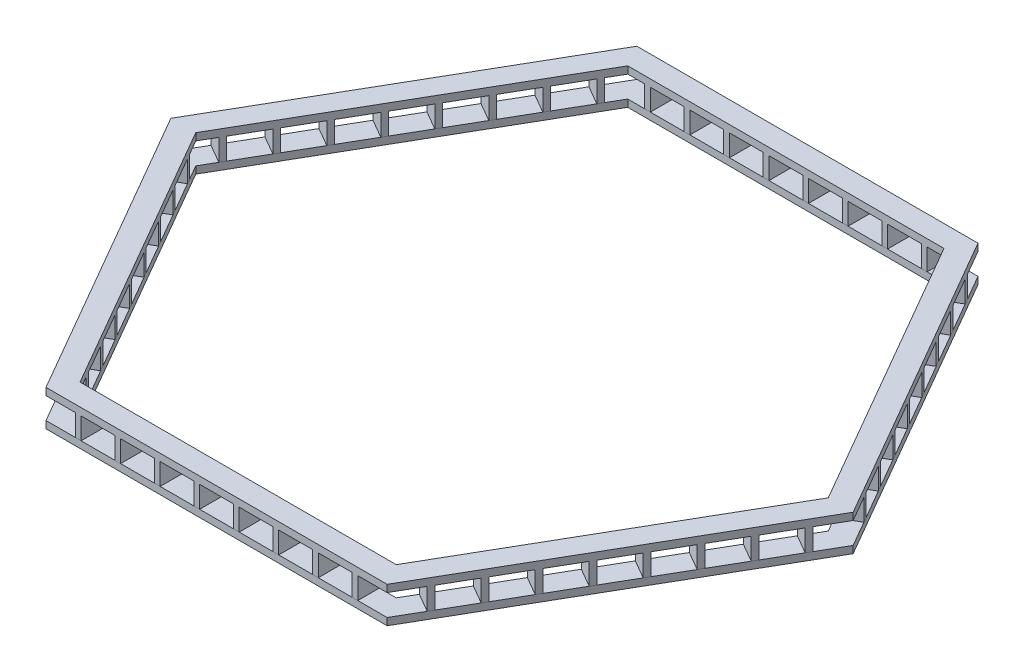
from build123d import *

# Parameters (mm, degrees)
EXTRUDE_2_DEPTH          = 50
SKETCH_2_W               = 40
SKETCH_2_H               = 150
EXTRUDE_3_DEPTH          = 150
EXTRUDE_3_2_DEPTH        = 150
EXTRUDE_3_3_DEPTH        = 150
EXTRUDE_3_4_DEPTH        = 150
EXTRUDE_3_5_DEPTH        = 150
EXTRUDE_3_6_DEPTH        = 150
EXTRUDE_3_7_DEPTH        = 150
EXTRUDE_3_8_DEPTH        = 150
PATTERN_CIRCULAR_2_COUNT = 6
EXTRUDE_5_DEPTH          = 50


with BuildPart() as part:
    # 草图1 → 凸台-拉伸2 (new body)
    with BuildSketch(Plane(origin=(0, 0, 0), x_dir=(1, 0, 0), z_dir=(0, 1, 0))):
        Polygon((-1186.602540378, -2055.255888326), (1186.602540378, -2055.255888326), (2373.205080757, 0), (1186.602540378, 2055.255888326), (-1186.602540378, 2055.255888326), (-2373.205080757, 0), align=None)
        Polygon((-1100, -1905.255888326), (1100, -1905.255888326), (2200, 0), (1100, 1905.255888326), (-1100, 1905.255888326), (-2200, 0), align=None, mode=Mode.SUBTRACT)
    extrude(amount=EXTRUDE_2_DEPTH)


with BuildPart() as body_2:
    # 草图2 → 凸台-拉伸3 (new body)
    with BuildSketch(Plane(origin=(0, 50, 0), x_dir=(1, 0, 0), z_dir=(0, 1, 0))):
        with Locations((137.5, 1980.255888326)):
            Rectangle(SKETCH_2_W, SKETCH_2_H)
    extrude(amount=EXTRUDE_3_DEPTH)


with BuildPart() as body_3:
    # 草图2 → Extrude 3 2 (new body)
    with BuildSketch(Plane(origin=(0, 50, 0), x_dir=(1, 0, 0), z_dir=(0, 1, 0))):
        with Locations((412.5, 1980.255888326)):
            Rectangle(SKETCH_2_W, SKETCH_2_H)
    extrude(amount=EXTRUDE_3_2_DEPTH)


with BuildPart() as body_4:
    # 草图2 → Extrude 3 3 (new body)
    with BuildSketch(Plane(origin=(0, 50, 0), x_dir=(1, 0, 0), z_dir=(0, 1, 0))):
        with Locations((687.5, 1980.255888326)):
            Rectangle(SKETCH_2_W, SKETCH_2_H)
    extrude(amount=EXTRUDE_3_3_DEPTH)


with BuildPart() as body_5:
    # 草图2 → Extrude 3 4 (new body)
    with BuildSketch(Plane(origin=(0, 50, 0), x_dir=(1, 0, 0), z_dir=(0, 1, 0))):
        with Locations((962.5, 1980.255888326)):
            Rectangle(SKETCH_2_W, SKETCH_2_H)
    extrude(amount=EXTRUDE_3_4_DEPTH)


with BuildPart() as body_6:
    # 草图2 → Extrude 3 5 (new body)
    with BuildSketch(Plane(origin=(0, 50, 0), x_dir=(1, 0, 0), z_dir=(0, 1, 0))):
        with Locations((-412.5, 1980.255888326)):
            Rectangle(SKETCH_2_W, SKETCH_2_H)
    extrude(amount=EXTRUDE_3_5_DEPTH)


with BuildPart() as body_7:
    # 草图2 → Extrude 3 6 (new body)
    with BuildSketch(Plane(origin=(0, 50, 0), x_dir=(1, 0, 0), z_dir=(0, 1, 0))):
        with Locations((-962.5, 1980.255888326)):
            Rectangle(SKETCH_2_W, SKETCH_2_H)
    extrude(amount=EXTRUDE_3_6_DEPTH)


with BuildPart() as body_8:
    # 草图2 → Extrude 3 7 (new body)
    with BuildSketch(Plane(origin=(0, 50, 0), x_dir=(1, 0, 0), z_dir=(0, 1, 0))):
        with Locations((-687.5, 1980.255888326)):
            Rectangle(SKETCH_2_W, SKETCH_2_H)
    extrude(amount=EXTRUDE_3_7_DEPTH)


with BuildPart() as body_9:
    # 草图2 → Extrude 3 8 (new body)
    with BuildSketch(Plane(origin=(0, 50, 0), x_dir=(1, 0, 0), z_dir=(0, 1, 0))):
        with Locations((-137.5, 1980.255888326)):
            Rectangle(SKETCH_2_W, SKETCH_2_H)
    extrude(amount=EXTRUDE_3_8_DEPTH)


with BuildPart() as pattern_circular_2_1:
    # 阵列(圆周)2: pattern copy
    add(body_5.part.rotate(Axis((0, 0, 0), (0, 1, 0)), 1 * 360 / PATTERN_CIRCULAR_2_COUNT))


with BuildPart() as pattern_circular_2_2:
    # 阵列(圆周)2: pattern copy
    add(body_5.part.rotate(Axis((0, 0, 0), (0, 1, 0)), 2 * 360 / PATTERN_CIRCULAR_2_COUNT))


with BuildPart() as pattern_circular_2_3:
    # 阵列(圆周)2: pattern copy
    add(body_5.part.rotate(Axis((0, 0, 0), (0, 1, 0)), 3 * 360 / PATTERN_CIRCULAR_2_COUNT))


with BuildPart() as pattern_circular_2_4:
    # 阵列(圆周)2: pattern copy
    add(body_5.part.rotate(Axis((0, 0, 0), (0, 1, 0)), 4 * 360 / PATTERN_CIRCULAR_2_COUNT))


with BuildPart() as pattern_circular_2_5:
    # 阵列(圆周)2: pattern copy
    add(body_5.part.rotate(Axis((0, 0, 0), (0, 1, 0)), 5 * 360 / PATTERN_CIRCULAR_2_COUNT))


with BuildPart() as pattern_circular_2_6:
    # 阵列(圆周)2: pattern copy
    add(body_3.part.rotate(Axis((0, 0, 0), (0, 1, 0)), 1 * 360 / PATTERN_CIRCULAR_2_COUNT))


with BuildPart() as pattern_circular_2_7:
    # 阵列(圆周)2: pattern copy
    add(body_3.part.rotate(Axis((0, 0, 0), (0, 1, 0)), 2 * 360 / PATTERN_CIRCULAR_2_COUNT))


with BuildPart() as pattern_circular_2_8:
    # 阵列(圆周)2: pattern copy
    add(body_3.part.rotate(Axis((0, 0, 0), (0, 1, 0)), 3 * 360 / PATTERN_CIRCULAR_2_COUNT))


with BuildPart() as pattern_circular_2_9:
    # 阵列(圆周)2: pattern copy
    add(body_3.part.rotate(Axis((0, 0, 0), (0, 1, 0)), 4 * 360 / PATTERN_CIRCULAR_2_COUNT))


with BuildPart() as pattern_circular_2_10:
    # 阵列(圆周)2: pattern copy
    add(body_3.part.rotate(Axis((0, 0, 0), (0, 1, 0)), 5 * 360 / PATTERN_CIRCULAR_2_COUNT))


with BuildPart() as pattern_circular_2_11:
    # 阵列(圆周)2: pattern copy
    add(body_7.part.rotate(Axis((0, 0, 0), (0, 1, 0)), 1 * 360 / PATTERN_CIRCULAR_2_COUNT))


with BuildPart() as pattern_circular_2_12:
    # 阵列(圆周)2: pattern copy
    add(body_7.part.rotate(Axis((0, 0, 0), (0, 1, 0)), 2 * 360 / PATTERN_CIRCULAR_2_COUNT))


with BuildPart() as pattern_circular_2_13:
    # 阵列(圆周)2: pattern copy
    add(body_7.part.rotate(Axis((0, 0, 0), (0, 1, 0)), 3 * 360 / PATTERN_CIRCULAR_2_COUNT))


with BuildPart() as pattern_circular_2_14:
    # 阵列(圆周)2: pattern copy
    add(body_7.part.rotate(Axis((0, 0, 0), (0, 1, 0)), 4 * 360 / PATTERN_CIRCULAR_2_COUNT))


with BuildPart() as pattern_circular_2_15:
    # 阵列(圆周)2: pattern copy
    add(body_7.part.rotate(Axis((0, 0, 0), (0, 1, 0)), 5 * 360 / PATTERN_CIRCULAR_2_COUNT))


with BuildPart() as pattern_circular_2_16:
    # 阵列(圆周)2: pattern copy
    add(body_8.part.rotate(Axis((0, 0, 0), (0, 1, 0)), 1 * 360 / PATTERN_CIRCULAR_2_COUNT))


with BuildPart() as pattern_circular_2_17:
    # 阵列(圆周)2: pattern copy
    add(body_8.part.rotate(Axis((0, 0, 0), (0, 1, 0)), 2 * 360 / PATTERN_CIRCULAR_2_COUNT))


with BuildPart() as pattern_circular_2_18:
    # 阵列(圆周)2: pattern copy
    add(body_8.part.rotate(Axis((0, 0, 0), (0, 1, 0)), 3 * 360 / PATTERN_CIRCULAR_2_COUNT))


with BuildPart() as pattern_circular_2_19:
    # 阵列(圆周)2: pattern copy
    add(body_8.part.rotate(Axis((0, 0, 0), (0, 1, 0)), 4 * 360 / PATTERN_CIRCULAR_2_COUNT))


with BuildPart() as pattern_circular_2_20:
    # 阵列(圆周)2: pattern copy
    add(body_8.part.rotate(Axis((0, 0, 0), (0, 1, 0)), 5 * 360 / PATTERN_CIRCULAR_2_COUNT))


with BuildPart() as pattern_circular_2_21:
    # 阵列(圆周)2: pattern copy
    add(body_6.part.rotate(Axis((0, 0, 0), (0, 1, 0)), 1 * 360 / PATTERN_CIRCULAR_2_COUNT))


with BuildPart() as pattern_circular_2_22:
    # 阵列(圆周)2: pattern copy
    add(body_6.part.rotate(Axis((0, 0, 0), (0, 1, 0)), 2 * 360 / PATTERN_CIRCULAR_2_COUNT))


with BuildPart() as pattern_circular_2_23:
    # 阵列(圆周)2: pattern copy
    add(body_6.part.rotate(Axis((0, 0, 0), (0, 1, 0)), 3 * 360 / PATTERN_CIRCULAR_2_COUNT))


with BuildPart() as pattern_circular_2_24:
    # 阵列(圆周)2: pattern copy
    add(body_6.part.rotate(Axis((0, 0, 0), (0, 1, 0)), 4 * 360 / PATTERN_CIRCULAR_2_COUNT))


with BuildPart() as pattern_circular_2_25:
    # 阵列(圆周)2: pattern copy
    add(body_6.part.rotate(Axis((0, 0, 0), (0, 1, 0)), 5 * 360 / PATTERN_CIRCULAR_2_COUNT))


with BuildPart() as pattern_circular_2_26:
    # 阵列(圆周)2: pattern copy
    add(body_9.part.rotate(Axis((0, 0, 0), (0, 1, 0)), 1 * 360 / PATTERN_CIRCULAR_2_COUNT))


with BuildPart() as pattern_circular_2_27:
    # 阵列(圆周)2: pattern copy
    add(body_9.part.rotate(Axis((0, 0, 0), (0, 1, 0)), 2 * 360 / PATTERN_CIRCULAR_2_COUNT))


with BuildPart() as pattern_circular_2_28:
    # 阵列(圆周)2: pattern copy
    add(body_9.part.rotate(Axis((0, 0, 0), (0, 1, 0)), 3 * 360 / PATTERN_CIRCULAR_2_COUNT))


with BuildPart() as pattern_circular_2_29:
    # 阵列(圆周)2: pattern copy
    add(body_9.part.rotate(Axis((0, 0, 0), (0, 1, 0)), 4 * 360 / PATTERN_CIRCULAR_2_COUNT))


with BuildPart() as pattern_circular_2_30:
    # 阵列(圆周)2: pattern copy
    add(body_9.part.rotate(Axis((0, 0, 0), (0, 1, 0)), 5 * 360 / PATTERN_CIRCULAR_2_COUNT))


with BuildPart() as pattern_circular_2_31:
    # 阵列(圆周)2: pattern copy
    add(body_2.part.rotate(Axis((0, 0, 0), (0, 1, 0)), 1 * 360 / PATTERN_CIRCULAR_2_COUNT))


with BuildPart() as pattern_circular_2_32:
    # 阵列(圆周)2: pattern copy
    add(body_2.part.rotate(Axis((0, 0, 0), (0, 1, 0)), 2 * 360 / PATTERN_CIRCULAR_2_COUNT))


with BuildPart() as pattern_circular_2_33:
    # 阵列(圆周)2: pattern copy
    add(body_2.part.rotate(Axis((0, 0, 0), (0, 1, 0)), 3 * 360 / PATTERN_CIRCULAR_2_COUNT))


with BuildPart() as pattern_circular_2_34:
    # 阵列(圆周)2: pattern copy
    add(body_2.part.rotate(Axis((0, 0, 0), (0, 1, 0)), 4 * 360 / PATTERN_CIRCULAR_2_COUNT))


with BuildPart() as pattern_circular_2_35:
    # 阵列(圆周)2: pattern copy
    add(body_2.part.rotate(Axis((0, 0, 0), (0, 1, 0)), 5 * 360 / PATTERN_CIRCULAR_2_COUNT))


with BuildPart() as pattern_circular_2_36:
    # 阵列(圆周)2: pattern copy
    add(body_4.part.rotate(Axis((0, 0, 0), (0, 1, 0)), 1 * 360 / PATTERN_CIRCULAR_2_COUNT))


with BuildPart() as pattern_circular_2_37:
    # 阵列(圆周)2: pattern copy
    add(body_4.part.rotate(Axis((0, 0, 0), (0, 1, 0)), 2 * 360 / PATTERN_CIRCULAR_2_COUNT))


with BuildPart() as pattern_circular_2_38:
    # 阵列(圆周)2: pattern copy
    add(body_4.part.rotate(Axis((0, 0, 0), (0, 1, 0)), 3 * 360 / PATTERN_CIRCULAR_2_COUNT))


with BuildPart() as pattern_circular_2_39:
    # 阵列(圆周)2: pattern copy
    add(body_4.part.rotate(Axis((0, 0, 0), (0, 1, 0)), 4 * 360 / PATTERN_CIRCULAR_2_COUNT))


with BuildPart() as pattern_circular_2_40:
    # 阵列(圆周)2: pattern copy
    add(body_4.part.rotate(Axis((0, 0, 0), (0, 1, 0)), 5 * 360 / PATTERN_CIRCULAR_2_COUNT))


with BuildPart() as body_2_1:
    add(body_2.part)

    add(body_3.part)  # 凸台-拉伸5 merges body 3

    add(body_4.part)  # 凸台-拉伸5 merges body 4

    add(body_5.part)  # 凸台-拉伸5 merges body 5

    add(body_6.part)  # 凸台-拉伸5 merges body 6

    add(body_7.part)  # 凸台-拉伸5 merges body 7

    add(body_8.part)  # 凸台-拉伸5 merges body 8

    add(body_9.part)  # 凸台-拉伸5 merges body 9

    add(pattern_circular_2_1.part)  # 凸台-拉伸5 merges 阵列(圆周)2_1

    add(pattern_circular_2_2.part)  # 凸台-拉伸5 merges 阵列(圆周)2_2

    add(pattern_circular_2_3.part)  # 凸台-拉伸5 merges 阵列(圆周)2_3

    add(pattern_circular_2_4.part)  # 凸台-拉伸5 merges 阵列(圆周)2_4

    add(pattern_circular_2_5.part)  # 凸台-拉伸5 merges 阵列(圆周)2_5

    add(pattern_circular_2_6.part)  # 凸台-拉伸5 merges 阵列(圆周)2_6

    add(pattern_circular_2_7.part)  # 凸台-拉伸5 merges 阵列(圆周)2_7

    add(pattern_circular_2_8.part)  # 凸台-拉伸5 merges 阵列(圆周)2_8

    add(pattern_circular_2_9.part)  # 凸台-拉伸5 merges 阵列(圆周)2_9

    add(pattern_circular_2_10.part)  # 凸台-拉伸5 merges 阵列(圆周)2_10

    add(pattern_circular_2_11.part)  # 凸台-拉伸5 merges 阵列(圆周)2_11

    add(pattern_circular_2_12.part)  # 凸台-拉伸5 merges 阵列(圆周)2_12

    add(pattern_circular_2_13.part)  # 凸台-拉伸5 merges 阵列(圆周)2_13

    add(pattern_circular_2_14.part)  # 凸台-拉伸5 merges 阵列(圆周)2_14

    add(pattern_circular_2_15.part)  # 凸台-拉伸5 merges 阵列(圆周)2_15

    add(pattern_circular_2_16.part)  # 凸台-拉伸5 merges 阵列(圆周)2_16

    add(pattern_circular_2_17.part)  # 凸台-拉伸5 merges 阵列(圆周)2_17

    add(pattern_circular_2_18.part)  # 凸台-拉伸5 merges 阵列(圆周)2_18

    add(pattern_circular_2_19.part)  # 凸台-拉伸5 merges 阵列(圆周)2_19

    add(pattern_circular_2_20.part)  # 凸台-拉伸5 merges 阵列(圆周)2_20

    add(pattern_circular_2_21.part)  # 凸台-拉伸5 merges 阵列(圆周)2_21

    add(pattern_circular_2_22.part)  # 凸台-拉伸5 merges 阵列(圆周)2_22

    add(pattern_circular_2_23.part)  # 凸台-拉伸5 merges 阵列(圆周)2_23

    add(pattern_circular_2_24.part)  # 凸台-拉伸5 merges 阵列(圆周)2_24

    add(pattern_circular_2_25.part)  # 凸台-拉伸5 merges 阵列(圆周)2_25

    add(pattern_circular_2_26.part)  # 凸台-拉伸5 merges 阵列(圆周)2_26

    add(pattern_circular_2_27.part)  # 凸台-拉伸5 merges 阵列(圆周)2_27

    add(pattern_circular_2_28.part)  # 凸台-拉伸5 merges 阵列(圆周)2_28

    add(pattern_circular_2_29.part)  # 凸台-拉伸5 merges 阵列(圆周)2_29

    add(pattern_circular_2_30.part)  # 凸台-拉伸5 merges 阵列(圆周)2_30

    add(pattern_circular_2_31.part)  # 凸台-拉伸5 merges 阵列(圆周)2_31

    add(pattern_circular_2_32.part)  # 凸台-拉伸5 merges 阵列(圆周)2_32

    add(pattern_circular_2_33.part)  # 凸台-拉伸5 merges 阵列(圆周)2_33

    add(pattern_circular_2_34.part)  # 凸台-拉伸5 merges 阵列(圆周)2_34

    add(pattern_circular_2_35.part)  # 凸台-拉伸5 merges 阵列(圆周)2_35

    add(pattern_circular_2_36.part)  # 凸台-拉伸5 merges 阵列(圆周)2_36

    add(pattern_circular_2_37.part)  # 凸台-拉伸5 merges 阵列(圆周)2_37

    add(pattern_circular_2_38.part)  # 凸台-拉伸5 merges 阵列(圆周)2_38

    add(pattern_circular_2_39.part)  # 凸台-拉伸5 merges 阵列(圆周)2_39

    add(pattern_circular_2_40.part)  # 凸台-拉伸5 merges 阵列(圆周)2_40
    # 草图5 → 凸台-拉伸5 (add)
    with BuildSketch(Plane(origin=(0, 200, 0), x_dir=(1, 0, 0), z_dir=(0, 1, 0))):
        Polygon((-2373.205080757, 0), (-1186.602540378, -2055.255888326), (1186.602540378, -2055.255888326), (2373.205080757, 0), (1186.602540378, 2055.255888326), (-1186.602540378, 2055.255888326), align=None)
        Polygon((-2200, 0), (-1100, -1905.255888326), (1100, -1905.255888326), (2200, 0), (1100, 1905.255888326), (-1100, 1905.255888326), align=None, mode=Mode.SUBTRACT)
    extrude(amount=EXTRUDE_5_DEPTH)


solid = Compound([part.part, body_2_1.part])
